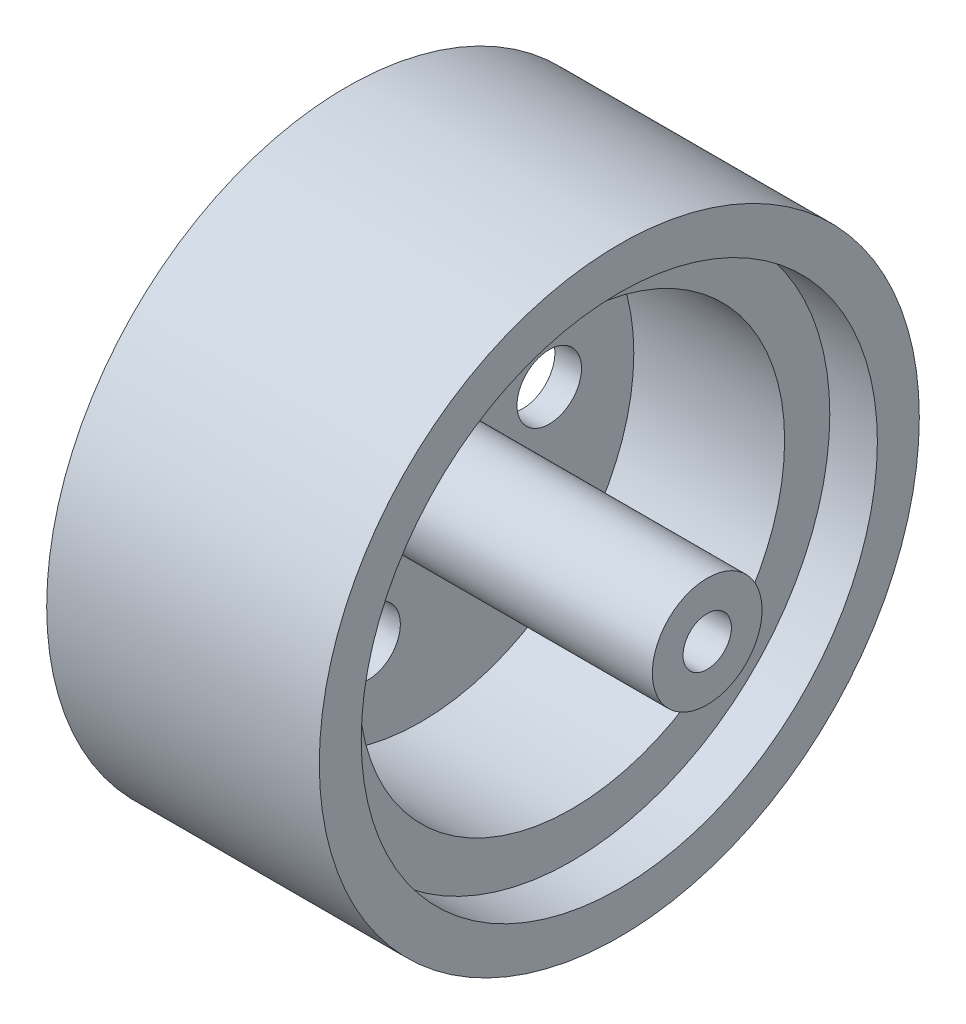
from build123d import *

# Parameters (mm, degrees)
SKETCH_1_R               = 16
EXTRUDE_1_DEPTH          = 11
SKETCH_2_R               = 13.2
CUT_EXTRUDE_1_DEPTH      = 9.35
SKETCH_3_R               = 2
CUT_EXTRUDE_3_DEPTH      = 9.35
PATTERN_CIRCULAR_3_COUNT = 3
SKETCH_4_R               = 3.4
EXTRUDE_2_DEPTH          = 17.75
SKETCH_5_R               = 1.5
CUT_EXTRUDE_4_DEPTH      = 25.75
SKETCH_6_R               = 18.6
SKETCH_6_R_2             = 16
EXTRUDE_4_DEPTH          = 2.95
EXTRUDE_4_DEPTH_BACK     = 13.95


with BuildPart() as part:
    # ｽｹｯﾁ1 → ﾎﾞｽ - 押し出し1 (new body)
    with BuildSketch(Plane(origin=(0, 0, 0), x_dir=(0, 0, -1), z_dir=(1, 0, 0))):
        Circle(SKETCH_1_R)
    extrude(amount=EXTRUDE_1_DEPTH)

    # ｽｹｯﾁ2 → ｶｯﾄ - 押し出し1 (cut)
    with BuildSketch(Plane(origin=(11, 0, 0), x_dir=(0, 0, -1), z_dir=(1, 0, 0))):
        Circle(SKETCH_2_R)
    extrude(amount=-CUT_EXTRUDE_1_DEPTH, mode=Mode.SUBTRACT)

    # ｽｹｯﾁ3 → ｶｯﾄ - 押し出し3 (cut)
    with BuildSketch(Plane.ZY):
        with Locations((4.685675375, 6.484168897)):
            Circle(SKETCH_3_R)
    cut_extrude_3 = extrude(amount=-CUT_EXTRUDE_3_DEPTH, mode=Mode.SUBTRACT)

    # 円形ﾊﾟﾀｰﾝ3: ｶｯﾄ - 押し出し3 ×3 about axis
    pattern_circular_3_axis = Axis((0, 0, 0), (1, 0, 0))
    for i in range(1, PATTERN_CIRCULAR_3_COUNT):
        add(cut_extrude_3.rotate(pattern_circular_3_axis, i * 360 / PATTERN_CIRCULAR_3_COUNT), mode=Mode.SUBTRACT)

    # ｽｹｯﾁ4 → ﾎﾞｽ - 押し出し2 (add)
    with BuildSketch(Plane(origin=(1.65, 0, 0), x_dir=(0, 0, -1), z_dir=(1, 0, 0))):
        Circle(SKETCH_4_R)
    extrude(amount=EXTRUDE_2_DEPTH)

    # ｽｹｯﾁ5 → ｶｯﾄ - 押し出し4 (cut)
    with BuildSketch(Plane(origin=(19.4, 0, 0), x_dir=(0, 0, -1), z_dir=(1, 0, 0))):
        Circle(SKETCH_5_R)
    extrude(amount=-CUT_EXTRUDE_4_DEPTH, mode=Mode.SUBTRACT)

    # ｽｹｯﾁ6 → ﾎﾞｽ - 押し出し4 (add, two sides)
    with BuildSketch(Plane.ZY) as extrude_4_sk:
        Circle(SKETCH_6_R)
        Circle(SKETCH_6_R_2, mode=Mode.SUBTRACT)
    extrude(amount=EXTRUDE_4_DEPTH)
    extrude(extrude_4_sk.sketch, amount=-EXTRUDE_4_DEPTH_BACK)


solid = part.part
